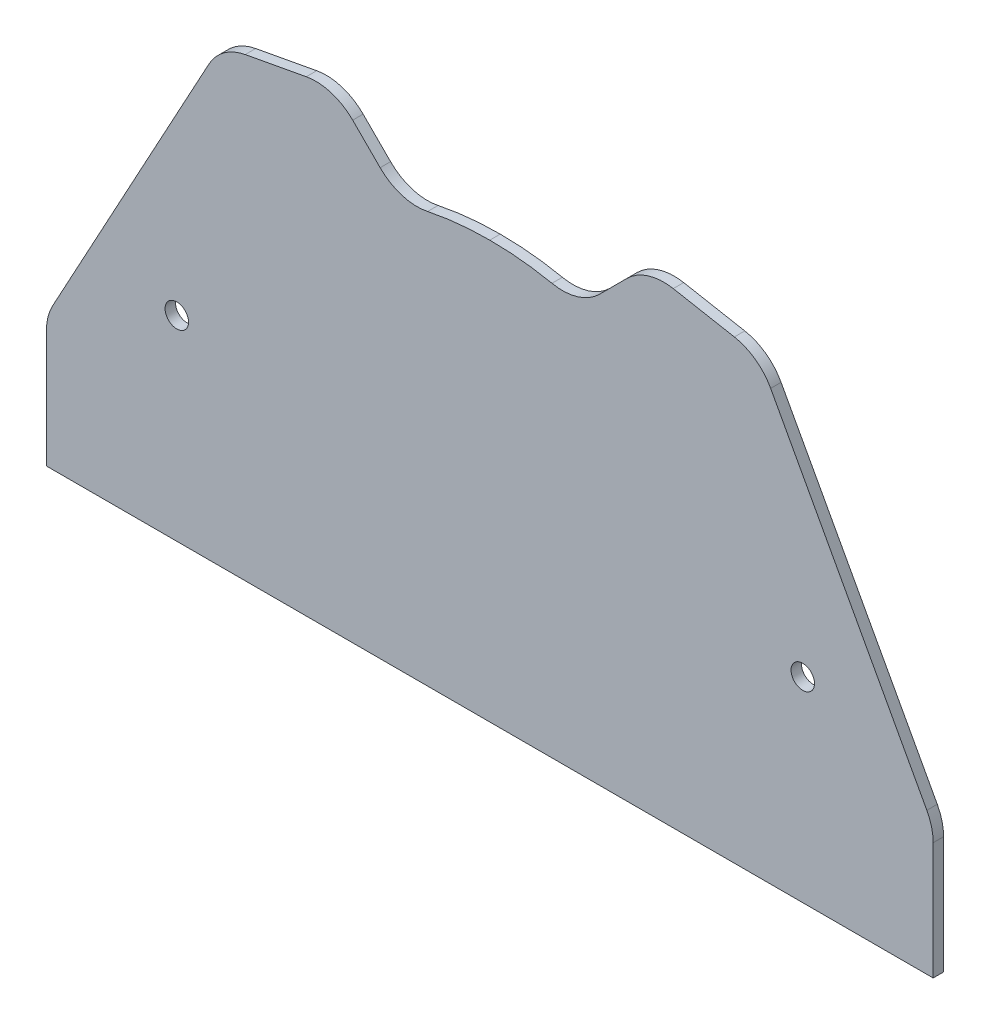
from build123d import *

# Parameters (mm, degrees)
CROQUIS1_R              = 2.25
SALIENTE_EXTRUIR1_DEPTH = 2
REDONDEO1_R             = 10


with BuildPart() as part:
    # Croquis1 → Saliente-Extruir1 (new body)
    with BuildSketch(Plane.XY):
        with BuildLine():
            Line((-85, 0), (85, 0))
            Line((85, 0), (85, 25))
            Line((85, 25), (51.567231643, 86.5))
            Line((51.567231643, 86.5), (30, 90.5))
            Line((30, 90.5), (17, 77.5))
            ThreePointArc((17, 77.5), (8.593451955, 79.385473293), (0, 80))
            ThreePointArc((0, 80), (-8.593451955, 79.385473293), (-17, 77.5))
            Line((-17, 77.5), (-30, 90.5))
            Line((-30, 90.5), (-51.567231643, 86.5))
            Line((-51.567231643, 86.5), (-85, 25))
            Line((-85, 25), (-85, 0))
        make_face()
        with Locations((-60, 37.5)):
            Circle(CROQUIS1_R, mode=Mode.SUBTRACT)
        with Locations((60, 37.5)):
            Circle(CROQUIS1_R, mode=Mode.SUBTRACT)
    extrude(amount=SALIENTE_EXTRUIR1_DEPTH)

    # Redondeo1
    redondeo1_edges = [part.edges().sort_by_distance(p)[0] for p in [
        (-85, 25, 1),
        (-51.567231643, 86.5, 1),
        (-30, 90.5, 1),
        (-17, 77.5, 1),
        (17, 77.5, 1),
        (30, 90.5, 1),
        (51.567231643, 86.5, 1),
        (85, 25, 1),
    ]]
    fillet(redondeo1_edges, radius=REDONDEO1_R)


solid = part.part
